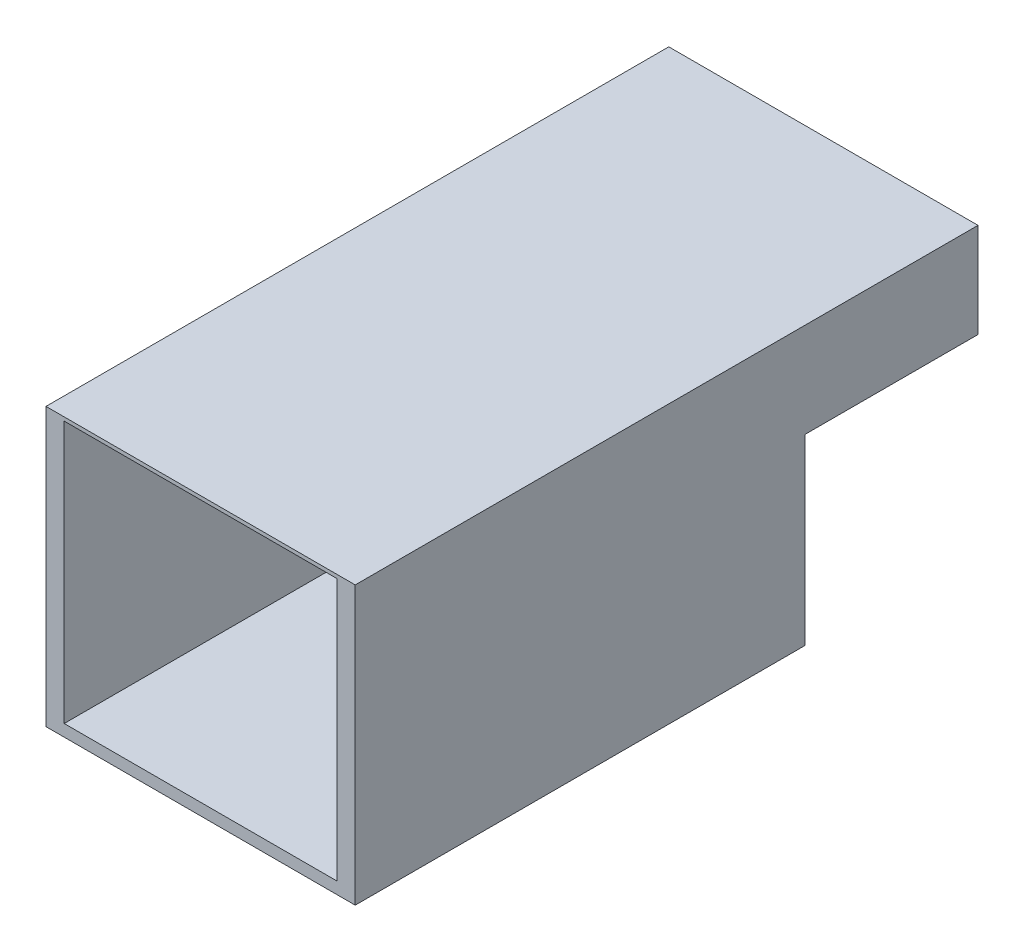
from build123d import *

# Parameters (mm, degrees)
BOSS_EXTRUDE1_DEPTH = 431.8
SKETCH2_W           = 381
SKETCH2_H           = 231.14
CUT_EXTRUDE1_DEPTH  = 203.2
SKETCH3_W           = 381
SKETCH3_H           = 365.76
CUT_EXTRUDE2_DEPTH  = 412.496


with BuildPart() as part:
    # Sketch1 → Boss-Extrude1 (new body)
    with BuildSketch(Plane(origin=(0, 0, 0), x_dir=(0, 0, -1), z_dir=(1, 0, 0))):
        Polygon((412.496, 387.35), (869.696, 387.35), (869.696, 255.27), (628.396, 255.27), (628.396, 0), (412.496, 0), (0, 0), (0, 387.35), align=None)
    extrude(amount=BOSS_EXTRUDE1_DEPTH)

    # Sketch2 → Cut-Extrude1 (cut)
    with BuildSketch(Plane(origin=(0, 0, -628.396), x_dir=(-1, 0, 0), z_dir=(0, 0, -1))):
        with Locations((-215.9, 132.08)):
            Rectangle(SKETCH2_W, SKETCH2_H)
    extrude(amount=-CUT_EXTRUDE1_DEPTH, mode=Mode.SUBTRACT)

    # Sketch3 → Cut-Extrude2 (cut)
    with BuildSketch(Plane.XY):
        with Locations((215.9, 199.39)):
            Rectangle(SKETCH3_W, SKETCH3_H)
    extrude(amount=-CUT_EXTRUDE2_DEPTH, mode=Mode.SUBTRACT)


solid = part.part
